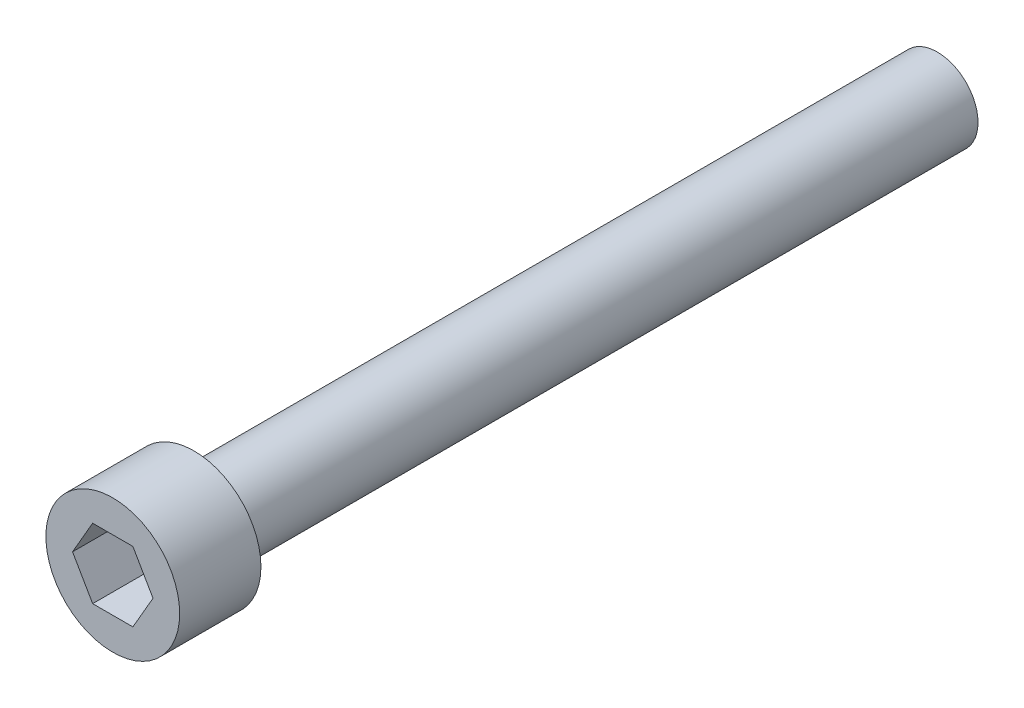
from build123d import *

# Parameters (mm, degrees)
F_9_64_ALLEN_DEPTH = 3.175


with BuildPart() as part:
    # Sketch1 → Revolve1 (revolve)
    with BuildSketch(Plane(origin=(0, 0, 0), x_dir=(1, 0, 0), z_dir=(0, 1, 0))):
        Polygon((0, 0), (0, 42.2656), (2.0828, 42.2656), (2.0828, 4.1656), (3.429, 4.1656), (3.429, 0), align=None)
    revolve(axis=Axis((0, 0, 0), (0, 0, -1)))

    # Sketch2 → 9-64 allen (cut)
    with BuildSketch(Plane.XY):
        Polygon((2.062222993, 0), (1.031111496, 1.7859375), (-1.031111496, 1.7859375), (-2.062222993, 0), (-1.031111496, -1.7859375), (1.031111496, -1.7859375), align=None)
    extrude(amount=-F_9_64_ALLEN_DEPTH, mode=Mode.SUBTRACT)


solid = part.part
